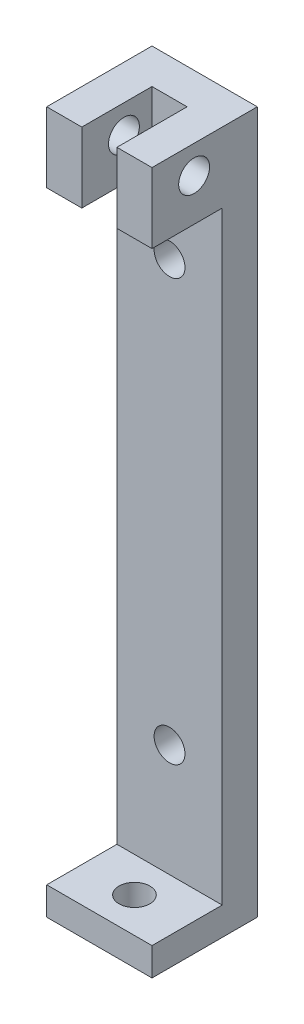
from build123d import *

# Parameters (mm, degrees)
SKIZZE1_W                       = 15
SKIZZE1_H                       = 15
AUFSATZ_LINEAR_AUSTRAGEN1_DEPTH = 4
SKIZZE2_W                       = 15
SKIZZE2_H                       = 5
AUFSATZ_LINEAR_AUSTRAGEN2_DEPTH = 96
SKIZZE3_W                       = 5
SKIZZE3_H                       = 10
AUFSATZ_LINEAR_AUSTRAGEN3_DEPTH = 10
SKIZZE4_R                       = 2.2
SCHNITT_LINEAR_AUSTRAGEN1_DEPTH = 5
SCHNITT_LINEAR_AUSTRAGEN2_REACH = 17
SKIZZE5_R                       = 2.2
SKIZZE6_R                       = 2.2
SCHNITT_LINEAR_AUSTRAGEN3_DEPTH = 16
SKIZZE7_R                       = 2.2
SCHNITT_LINEAR_AUSTRAGEN4_DEPTH = 6


with BuildPart() as part:
    # Skizze1 → Aufsatz-Linear austragen1 (new body)
    with BuildSketch(Plane(origin=(0, 0, 0), x_dir=(1, 0, 0), z_dir=(0, 1, 0))):
        Rectangle(SKIZZE1_W, SKIZZE1_H)
    extrude(amount=AUFSATZ_LINEAR_AUSTRAGEN1_DEPTH)

    # Skizze2 → Aufsatz-Linear austragen2 (add)
    with BuildSketch(Plane(origin=(0, 4, 0), x_dir=(1, 0, 0), z_dir=(0, 1, 0))):
        with Locations((0, 5)):
            Rectangle(SKIZZE2_W, SKIZZE2_H)
    extrude(amount=AUFSATZ_LINEAR_AUSTRAGEN2_DEPTH)

    # Skizze3 → Aufsatz-Linear austragen3 (add)
    with BuildSketch(Plane.XY.offset(-2.5)):
        with Locations((-5, 95)):
            Rectangle(SKIZZE3_W, SKIZZE3_H)
        with Locations((5, 95)):
            Rectangle(SKIZZE3_W, SKIZZE3_H)
    extrude(amount=AUFSATZ_LINEAR_AUSTRAGEN3_DEPTH)

    # Skizze4 → Schnitt-Linear austragen1 (cut, through all)
    with BuildSketch(Plane(origin=(0, 4, 0), x_dir=(1, 0, 0), z_dir=(0, 1, 0))):
        with Locations((0, -2.5)):
            Circle(SKIZZE4_R)
    extrude(amount=-SCHNITT_LINEAR_AUSTRAGEN1_DEPTH, mode=Mode.SUBTRACT)

    # Skizze5 → Schnitt-Linear austragen2 (cut, up to next)
    with BuildSketch(Plane(origin=(7.5, 0, 0), x_dir=(0, 0, -1), z_dir=(1, 0, 0)), mode=Mode.PRIVATE) as schnitt_linear_austragen2_sk1:
        with Locations((-1.5, 96)):
            Circle(SKIZZE5_R)
    schnitt_linear_austragen2_tool1 = extrude(schnitt_linear_austragen2_sk1.sketch, amount=-SCHNITT_LINEAR_AUSTRAGEN2_REACH, mode=Mode.PRIVATE) & part.part
    add(schnitt_linear_austragen2_tool1.solids().sort_by_distance((7.5, 96, 1.5))[0], mode=Mode.SUBTRACT)

    # Skizze6 → Schnitt-Linear austragen3 (cut, through all)
    with BuildSketch(Plane.ZY.offset(7.5)):
        with Locations((1.5, 96)):
            Circle(SKIZZE6_R)
    extrude(amount=-SCHNITT_LINEAR_AUSTRAGEN3_DEPTH, mode=Mode.SUBTRACT)

    # Skizze7 → Schnitt-Linear austragen4 (cut, through all)
    with BuildSketch(Plane.XY.offset(-2.5)):
        with Locations((0, 20)):
            Circle(SKIZZE7_R)
        with Locations((0, 80)):
            Circle(SKIZZE7_R)
    extrude(amount=-SCHNITT_LINEAR_AUSTRAGEN4_DEPTH, mode=Mode.SUBTRACT)


solid = part.part
